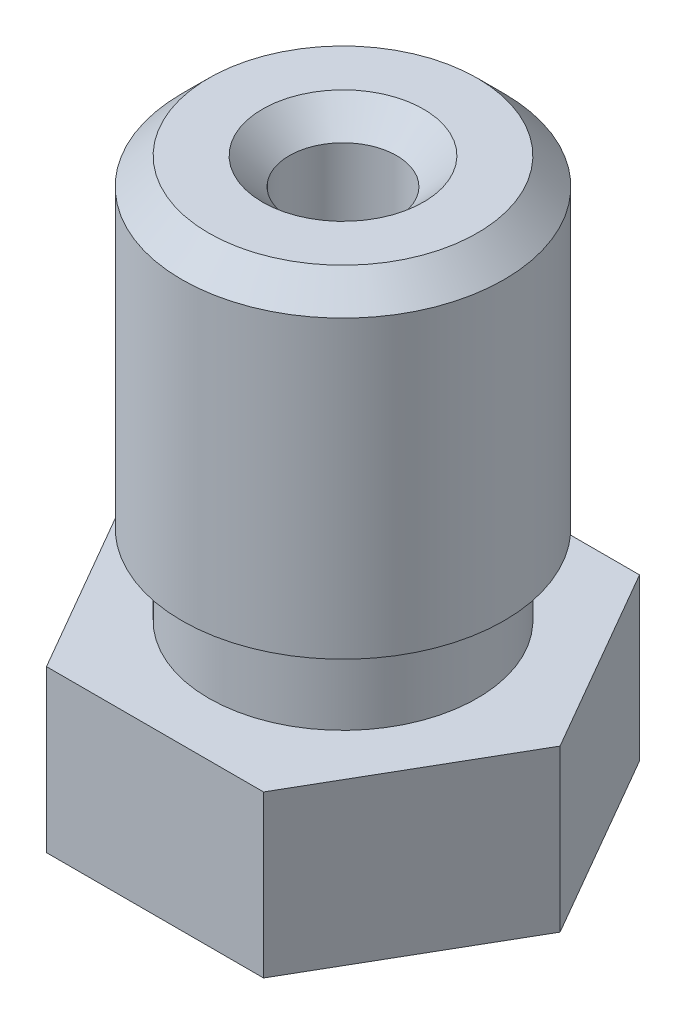
from build123d import *

# Parameters (mm, degrees)
BOSS_EXTRUDE1_DEPTH = 3
CHAMFER1_SIZE       = 0.5


with BuildPart() as part:
    # Sketch1 → Boss-Extrude1 (new body)
    with BuildSketch(Plane.XZ):
        Polygon((-2.020725942, 3.5), (-4.041451884, 0), (-2.020725942, -3.5), (2.020725942, -3.5), (4.041451884, 0), (2.020725942, 3.5), align=None)
    extrude(amount=-BOSS_EXTRUDE1_DEPTH)

    # Sketch2 → Revolve1 (revolve)
    with BuildSketch(Plane(origin=(0, 0, 0), x_dir=(-1, 0, 0), z_dir=(0, 0, -1))):
        Polygon((-2.5, 3), (0, 3), (0, 10.5), (-3, 10.5), (-3, 4.5), (-2.5, 4.5), align=None)
    revolve(axis=Axis((0, 3, 0), (0, 1, 0)))

    # Sketch3 → Revolve2 (revolve)
    with BuildSketch(Plane.XY):
        Polygon((2.5, 0), (0, 0), (0, -2), (0.5, -2), align=None)
    revolve(axis=Axis((0, 0, 0), (0, -1, 0)))

    # Sketch4 → Cut-Revolve1 (revolve, cut)
    with BuildSketch(Plane(origin=(0, 0, 0), x_dir=(-1, 0, 0), z_dir=(0, 0, -1))):
        Polygon((-0.1, -2), (0, -2), (0, 10.5), (-1, 10.5), (-1, 0), (-0.75, -0.227272727), (-0.75, -0.7), (-0.1, -1.2), align=None)
    revolve(axis=Axis((0, -2, 0), (0, 1, 0)), mode=Mode.SUBTRACT)

    # Chamfer1
    chamfer1_edges = [part.edges().sort_by_distance(p)[0] for p in [
        (-3, 10.5, 0),
        (-1, 10.5, 0),
    ]]
    chamfer(chamfer1_edges, length=CHAMFER1_SIZE)


solid = part.part
